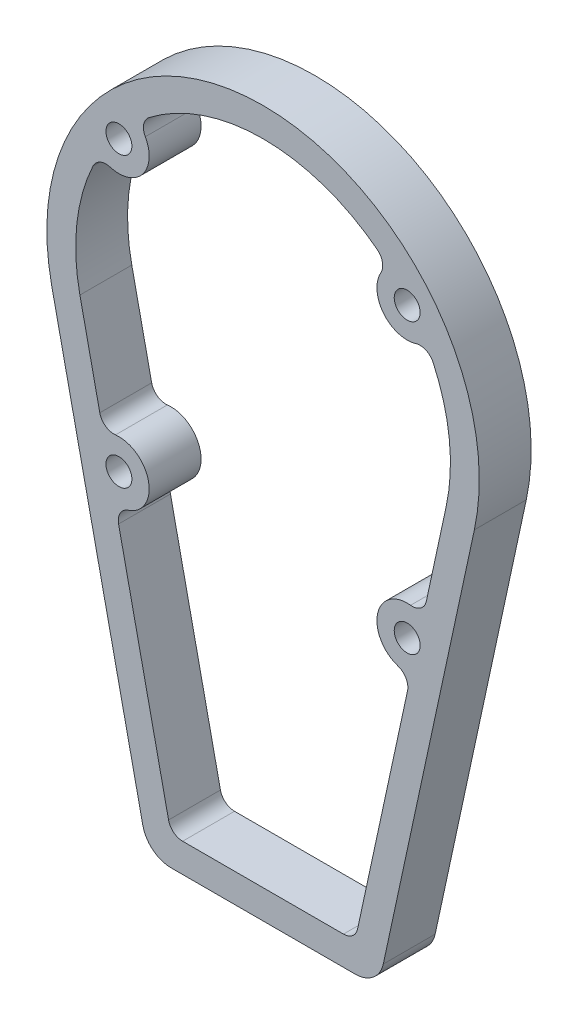
from build123d import *

# Parameters (mm, degrees)
SKETCH1_R           = 4.5
BOSS_EXTRUDE1_DEPTH = 18


with BuildPart() as part:
    # Sketch1 → Boss-Extrude1 (new body)
    with BuildSketch(Plane.XY.offset(18)):
        with BuildLine():
            Line((-73.308387301, 31.660797012), (-41.704324989, -114.611893732))
            ThreePointArc((-41.704324989, -114.611893732), (-38.210043039, -120.281996444), (-31.929873349, -122.5))
            Line((-31.929873349, -122.5), (31.929873349, -122.5))
            ThreePointArc((31.929873349, -122.5), (38.210043039, -120.281996444), (41.704324989, -114.611893732))
            Line((41.704324989, -114.611893732), (73.308387301, 31.660797012))
            ThreePointArc((73.308387301, 31.660797012), (0, 122.5), (-73.308387301, 31.660797012))
        make_face()
        with Locations((-50, -12.5)):
            Circle(SKETCH1_R, mode=Mode.SUBTRACT)
        with Locations((50, 87.5)):
            Circle(SKETCH1_R, mode=Mode.SUBTRACT)
        with Locations((50, -12.5)):
            Circle(SKETCH1_R, mode=Mode.SUBTRACT)
        with Locations((-50, 87.5)):
            Circle(SKETCH1_R, mode=Mode.SUBTRACT)
        with BuildLine():
            Line((63.533935661, 33.772690744), (56.635583446, 1.845132499))
            ThreePointArc((56.635583446, 1.845132499), (54.663630533, -1.161085559), (51.184371295, -2.067010753))
            ThreePointArc((51.184371295, -2.067010753), (39.736825778, -10.282511582), (46.771441988, -22.491316888))
            ThreePointArc((46.771441988, -22.491316888), (49.566331597, -24.752851185), (50.121259231, -28.305033701))
            Line((50.121259231, -28.305033701), (32.782035843, -108.555946866))
            ThreePointArc((32.782035843, -108.555946866), (31.034894868, -111.390998222), (27.894810023, -112.5))
            Line((27.894810023, -112.5), (-27.894810023, -112.5))
            ThreePointArc((-27.894810023, -112.5), (-31.034894868, -111.390998222), (-32.782035843, -108.555946866))
            Line((-32.782035843, -108.555946866), (-50.121259231, -28.305033701))
            ThreePointArc((-50.121259231, -28.305033701), (-49.566331597, -24.752851185), (-46.771441988, -22.491316888))
            ThreePointArc((-46.771441988, -22.491316888), (-39.736825778, -10.282511582), (-51.184371295, -2.067010753))
            ThreePointArc((-51.184371295, -2.067010753), (-54.663630533, -1.161085559), (-56.635583446, 1.845132499))
            Line((-56.635583446, 1.845132499), (-63.533935661, 33.772690744))
            ThreePointArc((-63.533935661, 33.772690744), (-64.607519764, 54.632207931), (-59.0097537, 74.755255792))
            ThreePointArc((-59.0097537, 74.755255792), (-56.52196193, 77.218486659), (-53.028431594, 77.44621454))
            ThreePointArc((-53.028431594, 77.44621454), (-41.800877501, 80.940702001), (-40.856206486, 92.661495924))
            ThreePointArc((-40.856206486, 92.661495924), (-41.400905456, 96.11980725), (-39.543854024, 99.087630387))
            ThreePointArc((-39.543854024, 99.087630387), (0, 112.5), (39.543854024, 99.087630387))
            ThreePointArc((39.543854024, 99.087630387), (41.400905456, 96.11980725), (40.856206486, 92.661495924))
            ThreePointArc((40.856206486, 92.661495924), (41.800877501, 80.940702001), (53.028431594, 77.44621454))
            ThreePointArc((53.028431594, 77.44621454), (56.52196193, 77.218486659), (59.0097537, 74.755255792))
            ThreePointArc((59.0097537, 74.755255792), (64.607519764, 54.632207931), (63.533935661, 33.772690744))
        make_face(mode=Mode.SUBTRACT)
    extrude(amount=-BOSS_EXTRUDE1_DEPTH)


solid = part.part
